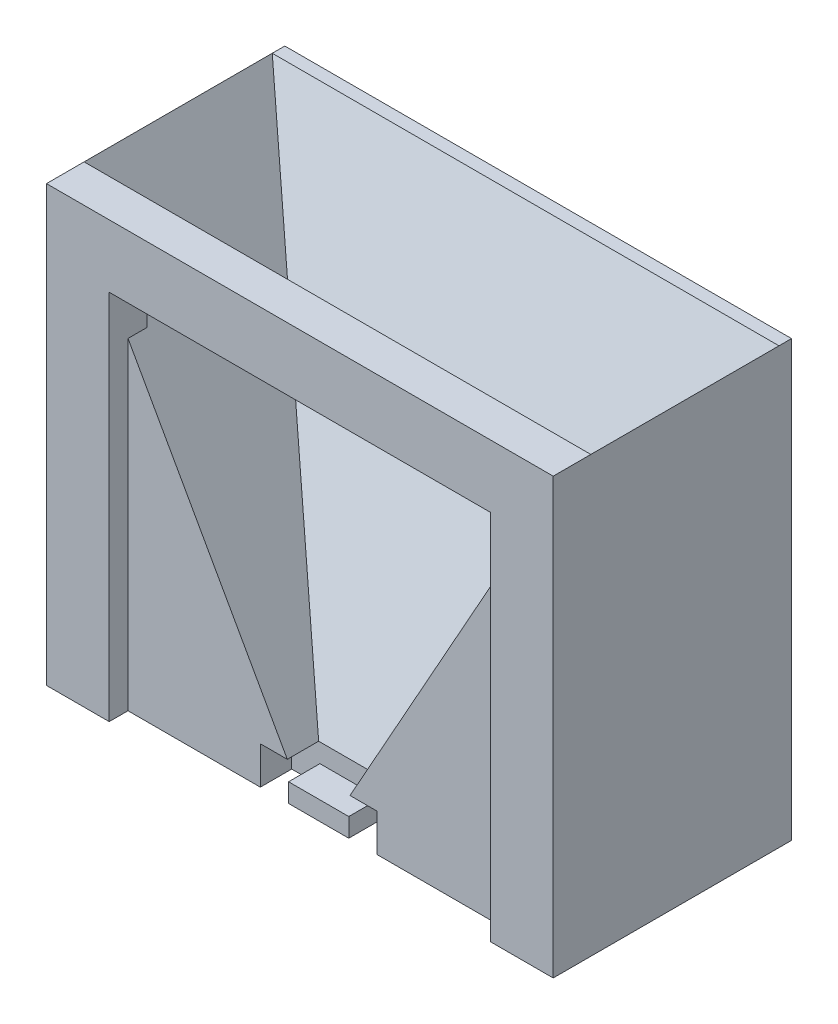
from build123d import *

# Parameters (mm, degrees)
BOSS_EXTRUDE1_DEPTH = 3
BOSS_EXTRUDE5_DEPTH = 35
BOSS_EXTRUDE6_DEPTH = 3
SKETCH8_W           = 80.8
SKETCH8_H           = 69.3
BOSS_EXTRUDE8_DEPTH = 2
BOSS_EXTRUDE9_DEPTH = 80.8
SKETCH10_W          = 4.5
SKETCH10_H          = 6
CUT_EXTRUDE1_DEPTH  = 5
SKETCH13_W          = 9.8
SKETCH13_H          = 3
CUT_EXTRUDE2_DEPTH  = 5


with BuildPart() as part:
    # Sketch1 → Boss-Extrude1 (new body)
    with BuildSketch(Plane.XY):
        Polygon((30.4, -26.4), (40.4, -26.4), (40.4, 41.4), (-40.4, 41.4), (-40.4, -26.4), (-30.4, -26.4), (-30.4, 31.4), (30.4, 31.4), align=None)
    extrude(amount=-BOSS_EXTRUDE1_DEPTH)

    # Sketch5 → Boss-Extrude5 (add)
    with BuildSketch(Plane.XY):
        Polygon((-40.4, 41.4), (-5, -21.9), (0, -21.9), (5, -21.9), (40.4, 41.4), (40.4, -27.9), (-40.4, -27.9), align=None)
    extrude(amount=-BOSS_EXTRUDE5_DEPTH)

    # Sketch6 → Boss-Extrude6 (add)
    with BuildSketch(Plane.XY):
        Polygon((-40.4, 41.4), (40.4, 41.4), (40.4, -27.9), (30.4, -27.9), (30.4, 31.4), (-30.4, 31.4), (-30.4, -27.9), (-40.4, -27.9), align=None)
    extrude(amount=BOSS_EXTRUDE6_DEPTH)

    # Sketch8 → Boss-Extrude8 (add)
    with BuildSketch(Plane(origin=(0, 0, -35), x_dir=(-1, 0, 0), z_dir=(0, 0, -1))):
        with Locations((0, 6.75)):
            Rectangle(SKETCH8_W, SKETCH8_H)
    extrude(amount=-BOSS_EXTRUDE8_DEPTH)

    # Sketch9 → Boss-Extrude9 (add)
    with BuildSketch(Plane(origin=(40.4, 0, 0), x_dir=(0, 0, -1), z_dir=(1, 0, 0))):
        Polygon((33, -21.9), (33, 41.4), (5, -21.9), align=None)
    extrude(amount=-BOSS_EXTRUDE9_DEPTH)

    # Sketch10 → Cut-Extrude1 (cut)
    with BuildSketch(Plane.XY):
        with Locations((7.05, -24.9)):
            Rectangle(SKETCH10_W, SKETCH10_H)
        with Locations((-7.05, -24.9)):
            Rectangle(SKETCH10_W, SKETCH10_H)
    extrude(amount=-CUT_EXTRUDE1_DEPTH, mode=Mode.SUBTRACT)

    # Sketch13 → Cut-Extrude2 (cut)
    with BuildSketch(Plane.XY.offset(-5)):
        with Locations((-0.1, -23.4)):
            Rectangle(SKETCH13_W, SKETCH13_H)
    extrude(amount=CUT_EXTRUDE2_DEPTH, mode=Mode.SUBTRACT)


solid = part.part
